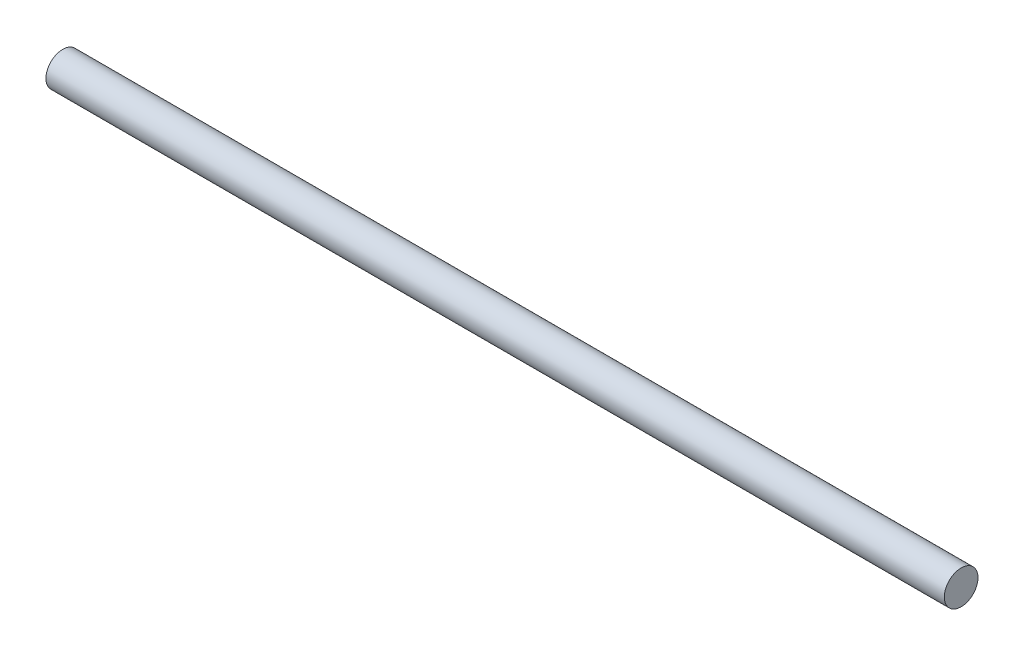
from build123d import *

# Parameters (mm, degrees)
ESQUISSE1_W = 80
ESQUISSE1_H = 1.5


with BuildPart() as part:
    # Esquisse1 → Révolution1 (revolve)
    with BuildSketch(Plane.XY):
        with Locations((40, 0.75)):
            Rectangle(ESQUISSE1_W, ESQUISSE1_H)
    revolve(axis=Axis((82.663287453, 0, 0), (-1, 0, 0)))


solid = part.part
